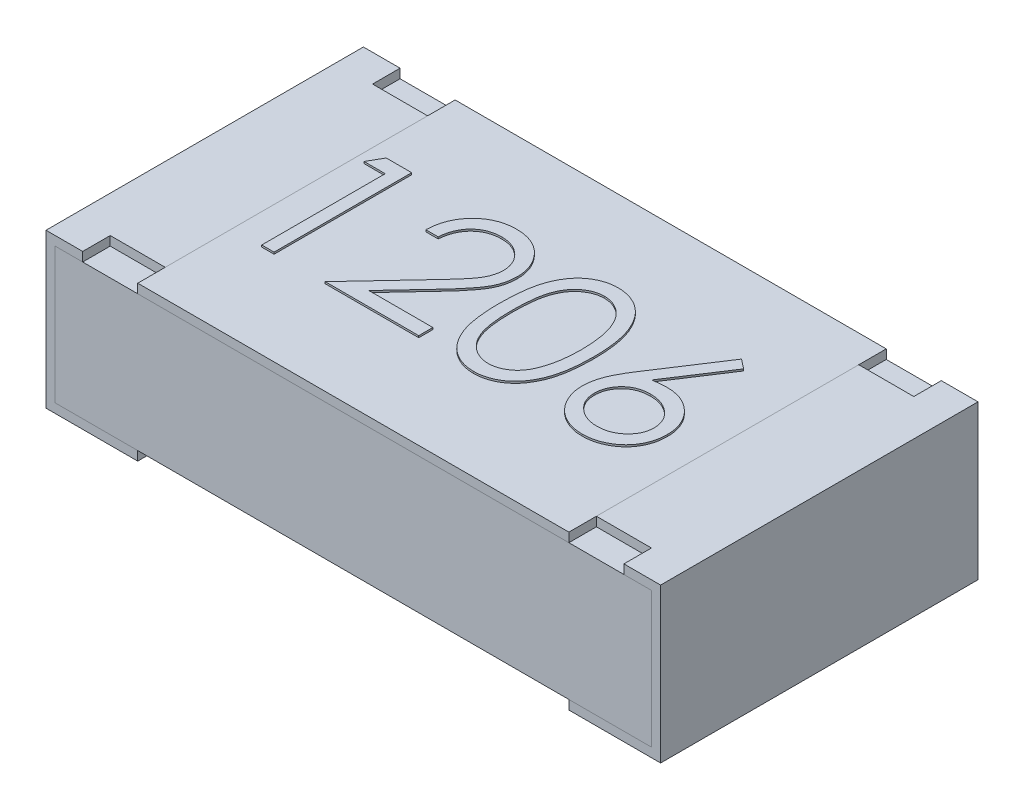
from build123d import *

# Parameters (mm, degrees)
CROQUIS1_W          = 3.25
CROQUIS1_H          = 1.73
EXTRUIR1_DEPTH      = 0.79
CROQUIS2_W          = 3.25
CROQUIS2_H          = 0.05
EXTRUIR2_DEPTH      = 3.501524535
CROQUIS4_W          = 1.73
CROQUIS4_H          = 0.05
EXTRUIR3_DEPTH      = 2.35
CROQUIS5_W          = 0.3
CROQUIS5_H          = 0.15
EXTRUIR4_DEPTH      = 0.05
BOSS_EXTRUDE1_DEPTH = 0.01


with BuildPart() as part:
    # Croquis1 → Extruir1 (new body)
    with BuildSketch(Plane(origin=(0, 0, 0), x_dir=(1, 0, 0), z_dir=(0, 1, 0))):
        Rectangle(CROQUIS1_W, CROQUIS1_H)
    extrude(amount=EXTRUIR1_DEPTH)

    # Croquis2 → Extruir2 (cut, through all)
    with BuildSketch(Plane.XY.offset(0.865)):
        with Locations((0, 0.025)):
            Rectangle(CROQUIS2_W, CROQUIS2_H)
    extrude(amount=-EXTRUIR2_DEPTH, mode=Mode.SUBTRACT)


with BuildPart() as body_2:
    # Barrer1: sweep along a path in Croquis3
    with BuildLine(Plane.XY.offset(0.865)) as barrer1_path:
        Line((-1.175, 0.84), (-1.675, 0.84))
        Line((-1.675, 0.84), (-1.675, 0))
        Line((-1.675, 0), (-1.175, 0))
    # Croquis3D1 → Barrer1 (sweep)
    with BuildSketch(Plane(origin=(-1.175, 0.84, 0.865), x_dir=(0, -0.02888967070388963, -0.9995826063545828), z_dir=(1, 0, 0))):
        Polygon((0, 0), (1.729277909, 0.04997913), (1.730722393, 0), (0.001444484, -0.04997913), align=None)
    sweep(path=barrer1_path.line, transition=Transition.RIGHT)


with BuildPart() as body_3:
    # Simetría1: mirrored copy
    add(body_2.part.mirror(Plane(origin=(0, 0.79, 0.865), x_dir=(0, 0, 1), z_dir=(1, 0, 0))))


with BuildPart() as body_4:
    # Croquis4 → Extruir3 (new body)
    with BuildSketch(Plane(origin=(-1.175, 0, 0), x_dir=(0, 0, -1), z_dir=(1, 0, 0))):
        with Locations((0, 0.815)):
            Rectangle(CROQUIS4_W, CROQUIS4_H)
    extrude(amount=EXTRUIR3_DEPTH)

    # Sketch1 → Boss-Extrude1 (add)
    with BuildSketch(Plane(origin=(0, 0.84, 0), x_dir=(1, 0, 0), z_dir=(0, 1, 0))):
        Polygon((-1.07874573, 0.393272708), (-0.940073855, 0.393272708), (-0.940073855, -0.356727292), (-1.007381548, -0.356727292), (-1.007381548, 0.316349631), (-1.122766163, 0.316349631), align=None)
        with BuildLine():
            Line((-0.565073855, 0.162503478), (-0.632381548, 0.162503478))
            add(Edge.make_bspline(
                [(-0.632381548, 0.162503478), (-0.631942872, 0.171432954), (-0.631081325, 0.188970207), (-0.627046691, 0.214539615), (-0.621273646, 0.238979929), (-0.613111192, 0.262094911), (-0.602974132, 0.284088941), (-0.590817698, 0.304874659), (-0.576419015, 0.32437277), (-0.560089001, 0.342402523), (-0.542352864, 0.358942716), (-0.523215877, 0.373225983), (-0.503106228, 0.385294055), (-0.482084929, 0.395382893), (-0.459914808, 0.402955717), (-0.436797053, 0.40857464), (-0.412630095, 0.411955285), (-0.396164376, 0.412318668), (-0.387790201, 0.412503478)],
                knots=[0, 0, 0, 0, 1.10065271, 2.161652631, 3.183658789, 4.190468796, 5.17591951, 6.163126047, 7.15150782, 8.156236427, 9.156009102, 10.134482811, 11.092018607, 12.041330605, 13.001268258, 13.972401359, 14.968799086, 16, 16, 16, 16], degree=3))
            add(Edge.make_bspline(
                [(-0.387790201, 0.412503478), (-0.379566328, 0.412310951), (-0.363406712, 0.411932644), (-0.339821994, 0.408683852), (-0.317369717, 0.403595511), (-0.296093767, 0.396456493), (-0.276163896, 0.38685983), (-0.257430386, 0.375331786), (-0.239670213, 0.361998965), (-0.223683045, 0.346301719), (-0.209002742, 0.329544065), (-0.196337973, 0.3116538), (-0.185492295, 0.293176096), (-0.176452078, 0.273970053), (-0.169797191, 0.253854833), (-0.164744718, 0.233123289), (-0.161888844, 0.21156083), (-0.161450539, 0.196966568), (-0.161227701, 0.189546747)],
                knots=[0, 0, 0, 0, 1.111607364, 2.184268762, 3.212621178, 4.221274766, 5.211760367, 6.196651075, 7.1921475, 8.207485113, 9.220403448, 10.201281604, 11.166441695, 12.114753415, 13.065576456, 14.026450734, 14.996634279, 16, 16, 16, 16], degree=3))
            add(Edge.make_bspline(
                [(-0.161227701, 0.189546747), (-0.161590543, 0.179100782), (-0.16230986, 0.158392165), (-0.168462941, 0.127960409), (-0.178072908, 0.098476105), (-0.18964377, 0.074746683), (-0.201316436, 0.05562522), (-0.211835188, 0.039881926), (-0.224149076, 0.022930754), (-0.238437326, 0.004828468), (-0.25440437, -0.014566726), (-0.272194833, -0.035243111), (-0.291935579, -0.056987062), (-0.305790972, -0.071838262), (-0.31297049, -0.079533782)],
                knots=[0, 0, 0, 0, 1.184426356, 2.348067706, 3.509069118, 4.696110526, 5.333549288, 6.050745305, 6.844228056, 7.710549037, 8.667450064, 9.695053472, 10.805634456, 12, 12, 12, 12], degree=3))
            Line((-0.31297049, -0.079533782), (-0.50062073, -0.279804215))
            Line((-0.50062073, -0.279804215), (-0.151612317, -0.279804215))
            Line((-0.151612317, -0.279804215), (-0.151612317, -0.356727292))
            Line((-0.151612317, -0.356727292), (-0.661227701, -0.356727292))
            Line((-0.661227701, -0.356727292), (-0.370362317, -0.046330657))
            add(Edge.make_bspline(
                [(-0.370362317, -0.046330657), (-0.363280627, -0.038938163), (-0.34967815, -0.024738694), (-0.330439026, -0.00400806), (-0.313159243, 0.015223985), (-0.297726944, 0.032921102), (-0.284476907, 0.049342152), (-0.272718572, 0.063955303), (-0.263297374, 0.077402685), (-0.253072646, 0.09298996), (-0.24316965, 0.112021171), (-0.23465986, 0.13527839), (-0.229470964, 0.159219944), (-0.228848499, 0.175398952), (-0.228535394, 0.183537131)],
                knots=[0, 0, 0, 0, 1.329631726, 2.553950428, 3.673215718, 4.687767853, 5.603093632, 6.413772471, 7.123043292, 7.734684054, 8.834405432, 9.900288307, 10.943827018, 12, 12, 12, 12], degree=3))
            add(Edge.make_bspline(
                [(-0.228535394, 0.183537131), (-0.228671624, 0.188654574), (-0.228940108, 0.198740071), (-0.231309615, 0.213527019), (-0.234890438, 0.227790908), (-0.240021564, 0.241575612), (-0.246794437, 0.254742537), (-0.255038733, 0.267307711), (-0.264550889, 0.279455347), (-0.275554733, 0.290845339), (-0.287642916, 0.301277026), (-0.300413112, 0.310517902), (-0.313923849, 0.318240568), (-0.328118161, 0.324571318), (-0.342956475, 0.329537471), (-0.358467492, 0.332978595), (-0.374608353, 0.335139127), (-0.385629816, 0.33543145), (-0.39124573, 0.335580401)],
                knots=[0, 0, 0, 0, 0.991446411, 1.95395049, 2.89581595, 3.838931463, 4.798493298, 5.75982156, 6.748411868, 7.785213223, 8.824556874, 9.840280684, 10.836137867, 11.835679398, 12.848801643, 13.863922112, 14.911575587, 16, 16, 16, 16], degree=3))
            add(Edge.make_bspline(
                [(-0.39124573, 0.335580401), (-0.397110909, 0.33542718), (-0.408629151, 0.335126278), (-0.425540372, 0.333021422), (-0.441673039, 0.32939017), (-0.457067732, 0.32442374), (-0.471750501, 0.318111194), (-0.485649939, 0.310248677), (-0.498734843, 0.3008665), (-0.511029813, 0.290229238), (-0.522357808, 0.278386181), (-0.53231071, 0.265184046), (-0.541007285, 0.250863885), (-0.548594978, 0.235464339), (-0.554756911, 0.218845672), (-0.559465443, 0.201066878), (-0.563191196, 0.182205153), (-0.564435879, 0.169179778), (-0.565073855, 0.162503478)],
                knots=[0, 0, 0, 0, 1.031018746, 2.02475058, 2.990194455, 3.934040569, 4.864654155, 5.795059489, 6.735614925, 7.690564532, 8.649604399, 9.611025574, 10.590972636, 11.591080095, 12.624614302, 13.701020113, 14.821632451, 16, 16, 16, 16], degree=3))
        make_face()
        with BuildLine():
            add(Edge.make_bspline(
                [(-0.084304625, 0.017972228), (-0.084234335, 0.029993096), (-0.084097796, 0.053343807), (-0.082578849, 0.087369088), (-0.080055561, 0.11928915), (-0.076597553, 0.149105521), (-0.072389414, 0.176825899), (-0.06677181, 0.202376204), (-0.060383352, 0.225874691), (-0.052979257, 0.247397987), (-0.044624731, 0.267236067), (-0.035531675, 0.285755753), (-0.025339219, 0.302929024), (-0.01462988, 0.319029979), (-0.002970151, 0.333795056), (0.009308162, 0.34743277), (0.022684278, 0.359627931), (0.036703494, 0.370737853), (0.051492736, 0.380477025), (0.066630451, 0.389055469), (0.08222083, 0.396384012), (0.098306441, 0.402146248), (0.114742703, 0.406905715), (0.131587075, 0.41016049), (0.148867367, 0.412208399), (0.160531246, 0.412404185), (0.166446577, 0.412503478)],
                knots=[0, 0, 0, 0, 1.646270934, 3.197905019, 4.663502075, 6.030701355, 7.308322542, 8.50163776, 9.611534131, 10.641858119, 11.616356847, 12.558055219, 13.465016945, 14.349605745, 15.204443733, 16.039544428, 16.859896111, 17.680448484, 18.487036065, 19.28249412, 20.06191084, 20.843045899, 21.620316918, 22.403196591, 23.190181807, 24, 24, 24, 24], degree=3))
            add(Edge.make_bspline(
                [(0.166446577, 0.412503478), (0.172411323, 0.412398946), (0.184273325, 0.412191065), (0.201810548, 0.410193077), (0.218942623, 0.406877837), (0.235596509, 0.402180485), (0.251909007, 0.39635284), (0.267752523, 0.389048458), (0.283225469, 0.380545843), (0.298081959, 0.370555012), (0.312485091, 0.359415953), (0.326081083, 0.346823953), (0.338871173, 0.332906156), (0.351015881, 0.317811471), (0.362170652, 0.301250381), (0.37279353, 0.283510929), (0.382301823, 0.264282886), (0.391459254, 0.243887072), (0.399363608, 0.221759145), (0.406492089, 0.198023839), (0.412251868, 0.172400799), (0.417049569, 0.145024461), (0.420766333, 0.115794286), (0.423473328, 0.084772933), (0.424903274, 0.051939992), (0.425172567, 0.029491881), (0.42531076, 0.017972228)],
                knots=[0, 0, 0, 0, 0.810914788, 1.612654377, 2.396697861, 3.181598691, 3.963628158, 4.749916497, 5.551656086, 6.361998678, 7.18212741, 8.025565596, 8.878627764, 9.750805457, 10.657531673, 11.591944965, 12.560506719, 13.57287815, 14.630710178, 15.753379473, 16.941251878, 18.199788006, 19.531962791, 20.947069417, 22.433333509, 24, 24, 24, 24], degree=3))
            add(Edge.make_bspline(
                [(0.42531076, 0.017972228), (0.425171135, 0.006502819), (0.424899081, -0.015844857), (0.423489358, -0.048530066), (0.420712508, -0.079386789), (0.417238939, -0.108489031), (0.412428019, -0.135715664), (0.406512626, -0.161160903), (0.3999447, -0.184934632), (0.391837244, -0.206842092), (0.38296352, -0.22718889), (0.373308835, -0.246188993), (0.362965301, -0.264010341), (0.351696284, -0.280510287), (0.339684839, -0.295805714), (0.326673884, -0.309626633), (0.313030187, -0.322306062), (0.298584669, -0.333588554), (0.28349648, -0.343463869), (0.268076678, -0.352295409), (0.252051667, -0.359416701), (0.235784606, -0.365531352), (0.219042813, -0.370202878), (0.201847158, -0.373432989), (0.184285107, -0.375698386), (0.172413343, -0.375871203), (0.166446577, -0.375958061)],
                knots=[0, 0, 0, 0, 1.561518951, 3.042555995, 4.452378317, 5.7783523, 7.031515105, 8.214008947, 9.334062868, 10.386615937, 11.391082383, 12.354592575, 13.286541444, 14.194233754, 15.072674879, 15.931287219, 16.775624067, 17.606195743, 18.42308326, 19.229000347, 20.022332153, 20.807536673, 21.593273796, 22.3848459, 23.188221202, 24, 24, 24, 24], degree=3))
            add(Edge.make_bspline(
                [(0.166446577, -0.375958061), (0.16053141, -0.375858128), (0.148867855, -0.375661079), (0.131585192, -0.373622422), (0.114810383, -0.370344814), (0.09846065, -0.365755542), (0.082452111, -0.360138077), (0.067002907, -0.35281943), (0.05194126, -0.344390701), (0.037307355, -0.334791682), (0.023376178, -0.323794179), (0.010069334, -0.311630403), (-0.002278884, -0.297996814), (-0.013771905, -0.283108688), (-0.024694924, -0.267102993), (-0.034742647, -0.249761199), (-0.044036401, -0.231152068), (-0.052531435, -0.211155373), (-0.060063291, -0.189479317), (-0.066716372, -0.165875922), (-0.071969405, -0.140136857), (-0.076465753, -0.11246885), (-0.080092406, -0.082753007), (-0.082568333, -0.050973198), (-0.084098615, -0.017149224), (-0.084234702, 0.006051441), (-0.084304625, 0.017972228)],
                knots=[0, 0, 0, 0, 0.810891512, 1.598919785, 2.382837074, 3.152667961, 3.926044502, 4.706494248, 5.493654104, 6.291793342, 7.103789334, 7.925228297, 8.761435821, 9.622817696, 10.50288917, 11.416980706, 12.369136599, 13.353924996, 14.394355917, 15.514179734, 16.714354668, 17.994756427, 19.357759367, 20.818452758, 22.365282078, 24, 24, 24, 24], degree=3))
        make_face()
        with BuildLine():
            add(Edge.make_bspline(
                [(-0.016996932, 0.018272708), (-0.016971336, 0.00825513), (-0.01692166, -0.011187022), (-0.015623903, -0.03943915), (-0.013855996, -0.065789934), (-0.011575718, -0.090272835), (-0.008189372, -0.112804981), (-0.00439506, -0.133541341), (0.000222388, -0.152372178), (0.005685606, -0.169426709), (0.011908269, -0.184994366), (0.018702383, -0.199480341), (0.026001109, -0.213055756), (0.034169499, -0.225598672), (0.043065584, -0.237149993), (0.052488425, -0.247914171), (0.062789693, -0.257513524), (0.077040495, -0.269026422), (0.095854025, -0.280923379), (0.119558409, -0.291283255), (0.143915934, -0.297793782), (0.160448344, -0.29862173), (0.168700183, -0.299034984)],
                knots=[0, 0, 0, 0, 1.459021318, 2.831673884, 4.118529203, 5.306027144, 6.411944654, 7.436330062, 8.375795394, 9.233974572, 10.042671642, 10.816086306, 11.563610507, 12.285937304, 12.993564865, 13.685989202, 14.367179055, 15.041617293, 16.353048772, 17.594441528, 18.799311195, 20, 20, 20, 20], degree=3))
            add(Edge.make_bspline(
                [(0.168700183, -0.299034984), (0.177005399, -0.298692602), (0.193598682, -0.298008546), (0.217841638, -0.291408817), (0.241376696, -0.281451058), (0.259820683, -0.269676593), (0.273852657, -0.258463379), (0.283906298, -0.248903097), (0.293133879, -0.238198269), (0.301885753, -0.22664842), (0.309912697, -0.214032887), (0.317211941, -0.200412335), (0.323872658, -0.18574894), (0.327667454, -0.175512567), (0.329607635, -0.170278974)],
                knots=[0, 0, 0, 0, 1.353760809, 2.704726607, 4.075137775, 5.516104923, 6.260822281, 7.007110065, 7.778089737, 8.566572457, 9.372053459, 10.217411131, 11.088608312, 12, 12, 12, 12], degree=3))
            add(Edge.make_bspline(
                [(0.329607635, -0.170278974), (0.331868728, -0.163586887), (0.336459717, -0.149999081), (0.342376526, -0.128921155), (0.347036254, -0.106806277), (0.351228404, -0.083786609), (0.354089773, -0.059692388), (0.356392876, -0.034598163), (0.357749452, -0.008485014), (0.357917613, 0.00925677), (0.358003068, 0.018272708)],
                knots=[0, 0, 0, 0, 0.884706709, 1.796334032, 2.740027952, 3.714592787, 4.726048262, 5.777819803, 6.87074269, 8, 8, 8, 8], degree=3))
            add(Edge.make_bspline(
                [(0.358003068, 0.018272708), (0.35788517, 0.027287188), (0.357654537, 0.044921438), (0.356772968, 0.070746762), (0.354496488, 0.095275568), (0.351968105, 0.118613527), (0.348240129, 0.140631449), (0.344220599, 0.161513657), (0.33882034, 0.181001448), (0.333051816, 0.19939993), (0.326449589, 0.21650007), (0.319181931, 0.232381596), (0.311420126, 0.247121179), (0.302989646, 0.260678381), (0.293990571, 0.273113926), (0.284185382, 0.284178482), (0.273963016, 0.294214975), (0.259645048, 0.30567124), (0.240900557, 0.317352318), (0.21757649, 0.328102123), (0.193304209, 0.334275329), (0.176895612, 0.33514569), (0.168700183, 0.335580401)],
                knots=[0, 0, 0, 0, 1.31362396, 2.569729283, 3.763502607, 4.902122613, 5.988968491, 7.01645872, 7.998833611, 8.933434873, 9.825090667, 10.667526885, 11.477055099, 12.250526234, 12.991942729, 13.710640831, 14.402115721, 15.076753259, 16.378508321, 17.609869233, 18.806226677, 20, 20, 20, 20], degree=3))
            add(Edge.make_bspline(
                [(0.168700183, 0.335580401), (0.160405056, 0.335145091), (0.143799691, 0.334273678), (0.119275129, 0.328125123), (0.095767054, 0.317408059), (0.077072131, 0.305632551), (0.062744176, 0.294417198), (0.052655028, 0.28469153), (0.043195134, 0.274053047), (0.034480627, 0.262395493), (0.026318637, 0.2498672), (0.018822706, 0.236369608), (0.012068993, 0.221834316), (0.005836592, 0.206273651), (0.000356709, 0.189220591), (-0.004163426, 0.17041295), (-0.008339223, 0.149742545), (-0.011295352, 0.127088364), (-0.0139233, 0.102599331), (-0.01561216, 0.076182763), (-0.016926001, 0.047883253), (-0.016972815, 0.028340576), (-0.016996932, 0.018272708)],
                knots=[0, 0, 0, 0, 1.207732386, 2.417664972, 3.655092373, 4.956220595, 5.625982001, 6.301752483, 6.994047911, 7.697131622, 8.419323945, 9.170223765, 9.943494443, 10.752040957, 11.610060368, 12.549350801, 13.567764191, 14.679664412, 15.874934091, 17.154273443, 18.533957287, 20, 20, 20, 20], degree=3))
        make_face(mode=Mode.SUBTRACT)
        with BuildLine():
            Line((0.838772299, 0.412503478), (0.890605231, 0.371788333))
            Line((0.890605231, 0.371788333), (0.692438164, 0.068753478))
            add(Edge.make_bspline(
                [(0.692438164, 0.068753478), (0.705631795, 0.070856448), (0.731367463, 0.074958529), (0.757417299, 0.075635231), (0.770112443, 0.075965016)],
                knots=[0, 0, 0, 0, 1.025318673, 2, 2, 2, 2], degree=3))
            add(Edge.make_bspline(
                [(0.770112443, 0.075965016), (0.777735121, 0.075760135), (0.792740135, 0.075356833), (0.814770164, 0.07225315), (0.835939222, 0.067362055), (0.856159567, 0.060232286), (0.875503778, 0.051124639), (0.894082862, 0.040209166), (0.911547579, 0.026922235), (0.928122832, 0.012079744), (0.943171495, -0.00435961), (0.956494936, -0.021802753), (0.967686391, -0.040231513), (0.976766517, -0.059636556), (0.983817563, -0.079987969), (0.988957772, -0.101259713), (0.991996256, -0.123466457), (0.992408862, -0.138568923), (0.992618452, -0.146240513)],
                knots=[0, 0, 0, 0, 1.04369286, 2.054478336, 3.041073146, 4.015093852, 4.984733326, 5.965804835, 6.960378782, 7.985147595, 9.009457201, 10.008161701, 10.986880575, 11.956520048, 12.937015923, 13.931873656, 14.949455224, 16, 16, 16, 16], degree=3))
            add(Edge.make_bspline(
                [(0.992618452, -0.146240513), (0.992313501, -0.156736164), (0.99171343, -0.177389121), (0.985734045, -0.207469843), (0.976442693, -0.236126811), (0.963161794, -0.262902491), (0.946665569, -0.287760184), (0.926548942, -0.309785641), (0.903525337, -0.32942922), (0.877492452, -0.345855639), (0.849476102, -0.359270578), (0.820043531, -0.368905987), (0.789480571, -0.374838159), (0.768736727, -0.37558186), (0.758243452, -0.375958061)],
                knots=[0, 0, 0, 0, 1.031375318, 2.029502543, 3.004789286, 3.987476834, 4.960371455, 5.9300674, 6.912260825, 7.929083631, 8.949397511, 9.960523116, 10.96833055, 12, 12, 12, 12], degree=3))
            add(Edge.make_bspline(
                [(0.758243452, -0.375958061), (0.748151302, -0.375630588), (0.72816052, -0.374981922), (0.698753493, -0.369203507), (0.670497132, -0.359837699), (0.643589407, -0.346934639), (0.618663562, -0.330636522), (0.596363782, -0.311016033), (0.576801259, -0.288492577), (0.560520983, -0.263069645), (0.547608398, -0.235750368), (0.537924842, -0.207263835), (0.532268505, -0.177713839), (0.5314781, -0.157682166), (0.531079991, -0.147592676)],
                knots=[0, 0, 0, 0, 1.012016664, 2.004627821, 2.994792927, 3.992885782, 4.990978636, 5.973936114, 6.964471063, 7.975201453, 8.993600317, 9.990122807, 10.98767138, 12, 12, 12, 12], degree=3))
            add(Edge.make_bspline(
                [(0.531079991, -0.147592676), (0.531333158, -0.139868837), (0.531850076, -0.124098233), (0.535459374, -0.100213084), (0.541258973, -0.075773567), (0.547754025, -0.055040525), (0.554616656, -0.038055913), (0.560327915, -0.024362308), (0.567436628, -0.01027065), (0.575016638, 0.004702272), (0.583750253, 0.020170579), (0.593246464, 0.036392794), (0.603767817, 0.053110922), (0.611143567, 0.064456106), (0.614914125, 0.070255881)],
                knots=[0, 0, 0, 0, 1.173818275, 2.396712641, 3.66331629, 4.989737886, 5.693666774, 6.447286557, 7.243889047, 8.091586357, 8.998013824, 9.943181721, 10.948533338, 12, 12, 12, 12], degree=3))
            Line((0.614914125, 0.070255881), (0.838772299, 0.412503478))
        make_face()
        with BuildLine():
            add(Edge.make_bspline(
                [(0.755989847, -0.000958061), (0.750276508, -0.001124784), (0.739116699, -0.001450444), (0.722743682, -0.00334157), (0.707247985, -0.006902798), (0.692424314, -0.01143844), (0.678549806, -0.01767481), (0.665523626, -0.025250196), (0.6532954, -0.03416902), (0.641993211, -0.044304929), (0.63174614, -0.055402365), (0.622921612, -0.067288691), (0.615309669, -0.079677449), (0.609120708, -0.092672151), (0.604301406, -0.106267829), (0.600815352, -0.120401954), (0.598875263, -0.135169306), (0.598552499, -0.145183413), (0.598387683, -0.150297003)],
                knots=[0, 0, 0, 0, 1.129588631, 2.206414736, 3.251139165, 4.268635594, 5.265702196, 6.250456724, 7.242448911, 8.251968645, 9.246821453, 10.222880186, 11.173611482, 12.116736599, 13.062300278, 14.020270554, 14.989073742, 16, 16, 16, 16], degree=3))
            add(Edge.make_bspline(
                [(0.598387683, -0.150297003), (0.598521903, -0.155364856), (0.59878509, -0.165302161), (0.601174872, -0.179946271), (0.604825247, -0.194038751), (0.610255332, -0.207506951), (0.616732522, -0.220556162), (0.625283663, -0.232713723), (0.634758689, -0.244718024), (0.646084532, -0.255646911), (0.658239538, -0.265816187), (0.67122551, -0.274704813), (0.684759787, -0.282308993), (0.699025092, -0.288268514), (0.713819031, -0.293159432), (0.729264864, -0.296601178), (0.745373333, -0.298547005), (0.756285177, -0.298870189), (0.761849222, -0.299034984)],
                knots=[0, 0, 0, 0, 0.989467248, 1.94019797, 2.891935182, 3.827694429, 4.772920941, 5.730924762, 6.725747692, 7.756678648, 8.79901574, 9.819492441, 10.826891316, 11.826466727, 12.835195252, 13.867842842, 14.912794438, 16, 16, 16, 16], degree=3))
            add(Edge.make_bspline(
                [(0.761849222, -0.299034984), (0.767413257, -0.298870176), (0.778325083, -0.298546967), (0.794433682, -0.296601323), (0.809879036, -0.293158899), (0.824674716, -0.288270448), (0.838933594, -0.282301817), (0.852456034, -0.27475212), (0.865319197, -0.265761524), (0.877482183, -0.255664289), (0.888760884, -0.244655821), (0.898463158, -0.23282088), (0.906752422, -0.220457903), (0.91348832, -0.207558355), (0.918858596, -0.194030608), (0.922527482, -0.179948452), (0.92491233, -0.16530159), (0.925176194, -0.155364663), (0.92531076, -0.150297003)],
                knots=[0, 0, 0, 0, 1.087397944, 2.132534446, 3.165364764, 4.174271784, 5.174024072, 6.181601208, 7.194203697, 8.236725232, 9.267838612, 10.269026844, 11.221737037, 12.171628256, 13.107553087, 14.05945871, 15.010357665, 16, 16, 16, 16], degree=3))
            add(Edge.make_bspline(
                [(0.92531076, -0.150297003), (0.92519284, -0.145176742), (0.924961402, -0.135127335), (0.922343698, -0.12040856), (0.91871319, -0.106196016), (0.913231112, -0.092579027), (0.906108995, -0.079611328), (0.897433979, -0.067227413), (0.887398428, -0.055332339), (0.875806099, -0.044283166), (0.863186763, -0.034180221), (0.849769137, -0.025261744), (0.835731714, -0.017734963), (0.821088727, -0.01145487), (0.805672395, -0.00692284), (0.789731608, -0.003354288), (0.773062484, -0.001455284), (0.761753211, -0.001125913), (0.755989847, -0.000958061)],
                knots=[0, 0, 0, 0, 0.978206639, 1.919901502, 2.851605144, 3.780102724, 4.718870031, 5.675451981, 6.667674623, 7.690630536, 8.733308323, 9.756129687, 10.767539656, 11.776269907, 12.797430371, 13.836405707, 14.897401972, 16, 16, 16, 16], degree=3))
        make_face(mode=Mode.SUBTRACT)
    extrude(amount=BOSS_EXTRUDE1_DEPTH)


with BuildPart() as extruir4_tool:
    # Croquis5 → Extruir4 (new body)
    with BuildSketch(Plane(origin=(0, 0.84, 0), x_dir=(1, 0, 0), z_dir=(0, 1, 0))):
        with Locations((-1.325, -0.79)):
            Rectangle(CROQUIS5_W, CROQUIS5_H)
        with Locations((-1.325, 0.79)):
            Rectangle(CROQUIS5_W, CROQUIS5_H)
        with Locations((1.325, 0.79)):
            Rectangle(CROQUIS5_W, CROQUIS5_H)
        with Locations((1.325, -0.79)):
            Rectangle(CROQUIS5_W, CROQUIS5_H)
    extrude(amount=-EXTRUIR4_DEPTH)


with BuildPart() as body_2_1:
    add(body_2.part)

    # Extruir4: cut by extruir4_tool
    add(extruir4_tool.part, mode=Mode.SUBTRACT)


with BuildPart() as body_3_1:
    add(body_3.part)

    # Extruir4: cut by extruir4_tool
    add(extruir4_tool.part, mode=Mode.SUBTRACT)


solid = Compound([part.part, body_4.part, body_2_1.part, body_3_1.part])
